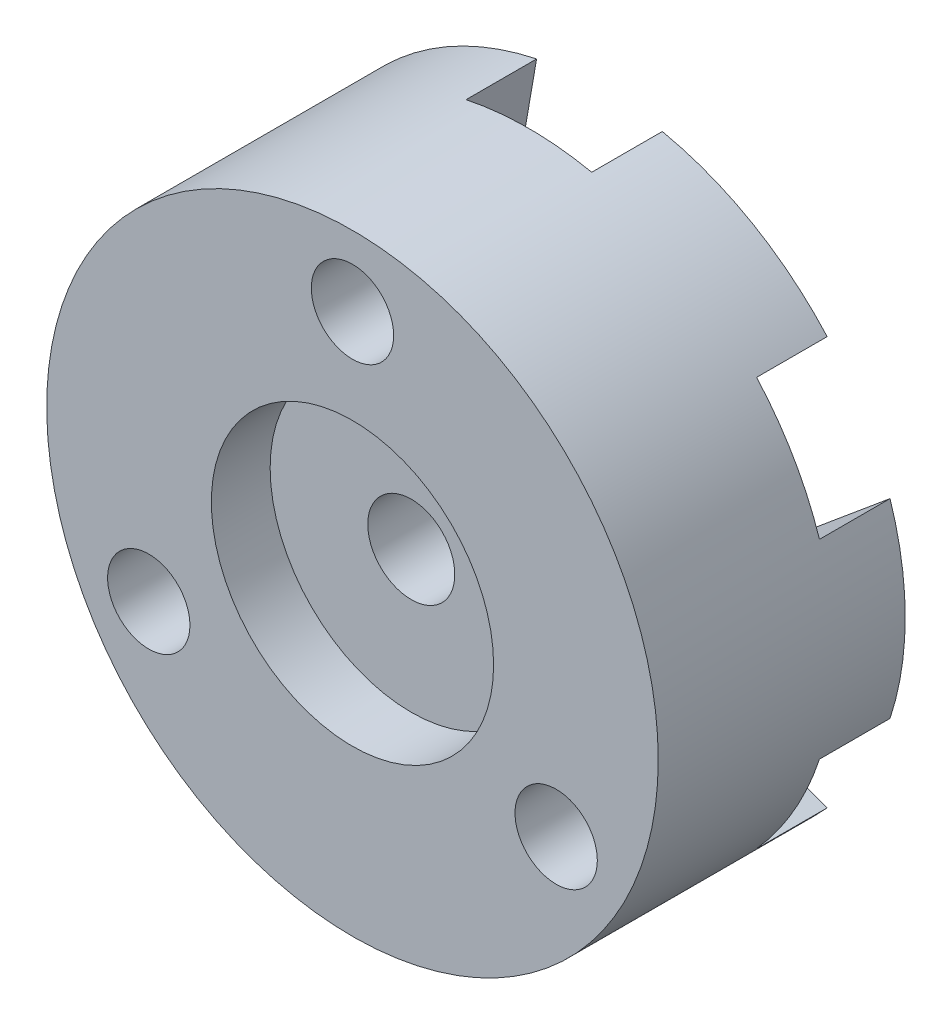
from build123d import *

# Parameters (mm, degrees)
SKETCH_3_R          = 13
EXTRUDE_1_DEPTH     = 7.5
SKETCH_4_R          = 1.75
CUT_EXTRUDE_1_DEPTH = 8.5
SKETCH_5_R          = 2.8
CUT_EXTRUDE_2_DEPTH = 2.6
SKETCH_6_R          = 6
CUT_EXTRUDE_3_DEPTH = 8.5
SKETCH_7_R          = 13
SKETCH_7_R_2        = 2.8
EXTRUDE_2_DEPTH     = 3
CUT_EXTRUDE_4_DEPTH = 4
SKETCH_8_R          = 6
SKETCH_8_R_2        = 1.85
EXTRUDE_3_DEPTH     = 5


with BuildPart() as part:
    # ｽｹｯﾁ3 → ﾎﾞｽ - 押し出し1 (new body)
    with BuildSketch(Plane.XY):
        Circle(SKETCH_3_R)
    extrude(amount=EXTRUDE_1_DEPTH)

    # ｽｹｯﾁ4 → ｶｯﾄ - 押し出し1 (cut, through all)
    with BuildSketch(Plane.XY.offset(7.5)):
        with Locations((0, 10)):
            Circle(SKETCH_4_R)
        with Locations((8.660254038, -5)):
            Circle(SKETCH_4_R)
        with Locations((-8.660254038, -5)):
            Circle(SKETCH_4_R)
    extrude(amount=-CUT_EXTRUDE_1_DEPTH, mode=Mode.SUBTRACT)

    # ｽｹｯﾁ5 → ｶｯﾄ - 押し出し2 (cut)
    with BuildSketch(Plane(origin=(0, 0, 0), x_dir=(-1, 0, 0), z_dir=(0, 0, -1))):
        with Locations((8.660254038, -5)):
            Circle(SKETCH_5_R)
        with Locations((0, 10)):
            Circle(SKETCH_5_R)
        with Locations((-8.660254038, -5)):
            Circle(SKETCH_5_R)
    extrude(amount=-CUT_EXTRUDE_2_DEPTH, mode=Mode.SUBTRACT)

    # ｽｹｯﾁ6 → ｶｯﾄ - 押し出し3 (cut, through all)
    with BuildSketch(Plane.XY.offset(7.5)):
        Circle(SKETCH_6_R)
    extrude(amount=-CUT_EXTRUDE_3_DEPTH, mode=Mode.SUBTRACT)

    # ｽｹｯﾁ7 → ﾎﾞｽ - 押し出し2 (add)
    with BuildSketch(Plane(origin=(0, 0, 0), x_dir=(-1, 0, 0), z_dir=(0, 0, -1))):
        Circle(SKETCH_7_R)
        with Locations((0, 10)):
            Circle(SKETCH_7_R_2, mode=Mode.SUBTRACT)
        with Locations((8.660254038, -5)):
            Circle(SKETCH_7_R_2, mode=Mode.SUBTRACT)
        with Locations((-8.660254038, -5)):
            Circle(SKETCH_7_R_2, mode=Mode.SUBTRACT)
    extrude(amount=EXTRUDE_2_DEPTH)

    # ｽｹｯﾁ2 → ｶｯﾄ - 押し出し4 (cut, through all)
    with BuildSketch(Plane.XY):
        with BuildLine():
            Line((-3.75, 6.495190528), (-2.463350586, 13.926501921))
            ThreePointArc((-2.463350586, 13.926501921), (0, 16), (2.463350586, 13.926501921))
            Line((2.463350586, 13.926501921), (3.75, 6.495190528))
            Line((3.75, 6.495190528), (10.829029157, 9.096575147))
            ThreePointArc((10.829029157, 9.096575147), (13.856406461, 8), (13.292379743, 4.829926775))
            Line((13.292379743, 4.829926775), (7.5, 0))
            Line((7.5, 0), (13.292379743, -4.829926775))
            ThreePointArc((13.292379743, -4.829926775), (13.856406461, -8), (10.829029157, -9.096575147))
            Line((10.829029157, -9.096575147), (3.75, -6.495190528))
            Line((3.75, -6.495190528), (2.463350586, -13.926501921))
            ThreePointArc((2.463350586, -13.926501921), (0, -16), (-2.463350586, -13.926501921))
            Line((-2.463350586, -13.926501921), (-3.75, -6.495190528))
            Line((-3.75, -6.495190528), (-10.829029157, -9.096575147))
            ThreePointArc((-10.829029157, -9.096575147), (-13.856406461, -8), (-13.292379743, -4.829926775))
            Line((-13.292379743, -4.829926775), (-7.5, 0))
            Line((-7.5, 0), (-13.292379743, 4.829926775))
            ThreePointArc((-13.292379743, 4.829926775), (-13.856406461, 8), (-10.829029157, 9.096575147))
            Line((-10.829029157, 9.096575147), (-3.75, 6.495190528))
        make_face()
    extrude(amount=-CUT_EXTRUDE_4_DEPTH, mode=Mode.SUBTRACT)

    # ｽｹｯﾁ8 → ﾎﾞｽ - 押し出し3 (add)
    with BuildSketch(Plane(origin=(0, 0, 0), x_dir=(-1, 0, 0), z_dir=(0, 0, -1))):
        Circle(SKETCH_8_R)
        Circle(SKETCH_8_R_2, mode=Mode.SUBTRACT)
    extrude(amount=-EXTRUDE_3_DEPTH)


solid = part.part
